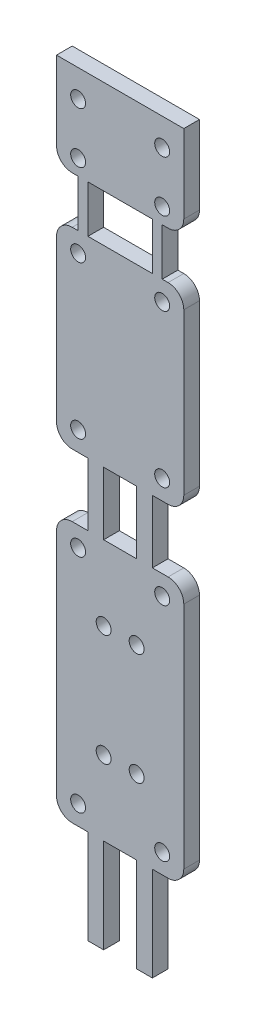
from build123d import *

# Parameters (mm, degrees)
SKETCH1_R           = 0.95
SKETCH1_W           = 4.2
SKETCH1_H           = 8
SKETCH1_W_2         = 8.2
SKETCH1_H_2         = 6
BOSS_EXTRUDE1_DEPTH = 2


with BuildPart() as part:
    # Sketch1 → Boss-Extrude1 (new body)
    with BuildSketch(Plane.XY):
        with BuildLine():
            Line((16.2, 109.64), (0, 109.64))
            Line((0, 109.64), (0, 99.66))
            ThreePointArc((0, 99.66), (0.585786438, 98.245786438), (2, 97.66))
            Line((2, 97.66), (2.75, 97.66))
            Line((2.75, 97.66), (2.75, 91.66))
            Line((2.75, 91.66), (2, 91.66))
            ThreePointArc((2, 91.66), (0.585786438, 91.074213562), (0, 89.66))
            Line((0, 89.66), (0, 69.21))
            ThreePointArc((0, 69.21), (0.585786438, 67.795786438), (2, 67.21))
            Line((2, 67.21), (4, 67.21))
            Line((4, 67.21), (4, 59.21))
            Line((4, 59.21), (2, 59.21))
            ThreePointArc((2, 59.21), (0.585786438, 58.624213562), (0, 57.21))
            Line((0, 57.21), (0, 28))
            ThreePointArc((0, 28), (0.585786438, 26.585786438), (2, 26))
            Line((2, 26), (4, 26))
            Line((4, 26), (4, 14))
            Line((4, 14), (6, 14))
            Line((6, 14), (6, 26))
            Line((6, 26), (10.2, 26))
            Line((10.2, 26), (10.2, 14))
            Line((10.2, 14), (12.2, 14))
            Line((12.2, 14), (12.2, 26))
            Line((12.2, 26), (14.2, 26))
            ThreePointArc((14.2, 26), (15.614213562, 26.585786438), (16.2, 28))
            Line((16.2, 28), (16.2, 57.21))
            ThreePointArc((16.2, 57.21), (15.614213562, 58.624213562), (14.2, 59.21))
            Line((14.2, 59.21), (12.2, 59.21))
            Line((12.2, 59.21), (12.2, 67.21))
            Line((12.2, 67.21), (14.2, 67.21))
            ThreePointArc((14.2, 67.21), (15.614213562, 67.795786438), (16.2, 69.21))
            Line((16.2, 69.21), (16.2, 89.66))
            ThreePointArc((16.2, 89.66), (15.614213562, 91.074213562), (14.2, 91.66))
            Line((14.2, 91.66), (13.45, 91.66))
            Line((13.45, 91.66), (13.45, 97.66))
            Line((13.45, 97.66), (14.2, 97.66))
            ThreePointArc((14.2, 97.66), (15.614213562, 98.245786438), (16.2, 99.66))
            Line((16.2, 99.66), (16.2, 109.64))
        make_face()
        with Locations((13.45, 56.71)):
            Circle(SKETCH1_R, mode=Mode.SUBTRACT)
        with Locations((10.2, 49.71)):
            Circle(SKETCH1_R, mode=Mode.SUBTRACT)
        with Locations((13.45, 106.16)):
            Circle(SKETCH1_R, mode=Mode.SUBTRACT)
        with Locations((2.75, 99.66)):
            Circle(SKETCH1_R, mode=Mode.SUBTRACT)
        with Locations((6, 49.71)):
            Circle(SKETCH1_R, mode=Mode.SUBTRACT)
        with Locations((2.75, 28.5)):
            Circle(SKETCH1_R, mode=Mode.SUBTRACT)
        with Locations((2.75, 89.16)):
            Circle(SKETCH1_R, mode=Mode.SUBTRACT)
        with Locations((2.75, 56.71)):
            Circle(SKETCH1_R, mode=Mode.SUBTRACT)
        with Locations((13.45, 89.16)):
            Circle(SKETCH1_R, mode=Mode.SUBTRACT)
        with Locations((13.45, 99.66)):
            Circle(SKETCH1_R, mode=Mode.SUBTRACT)
        with Locations((13.45, 69.71)):
            Circle(SKETCH1_R, mode=Mode.SUBTRACT)
        with Locations((6, 35.5)):
            Circle(SKETCH1_R, mode=Mode.SUBTRACT)
        with Locations((2.75, 106.16)):
            Circle(SKETCH1_R, mode=Mode.SUBTRACT)
        with Locations((10.2, 35.5)):
            Circle(SKETCH1_R, mode=Mode.SUBTRACT)
        with Locations((2.75, 69.71)):
            Circle(SKETCH1_R, mode=Mode.SUBTRACT)
        with Locations((13.45, 28.5)):
            Circle(SKETCH1_R, mode=Mode.SUBTRACT)
        with Locations((8.1, 63.21)):
            Rectangle(SKETCH1_W, SKETCH1_H, mode=Mode.SUBTRACT)
        with Locations((8.1, 94.66)):
            Rectangle(SKETCH1_W_2, SKETCH1_H_2, mode=Mode.SUBTRACT)
    extrude(amount=BOSS_EXTRUDE1_DEPTH)


solid = part.part
